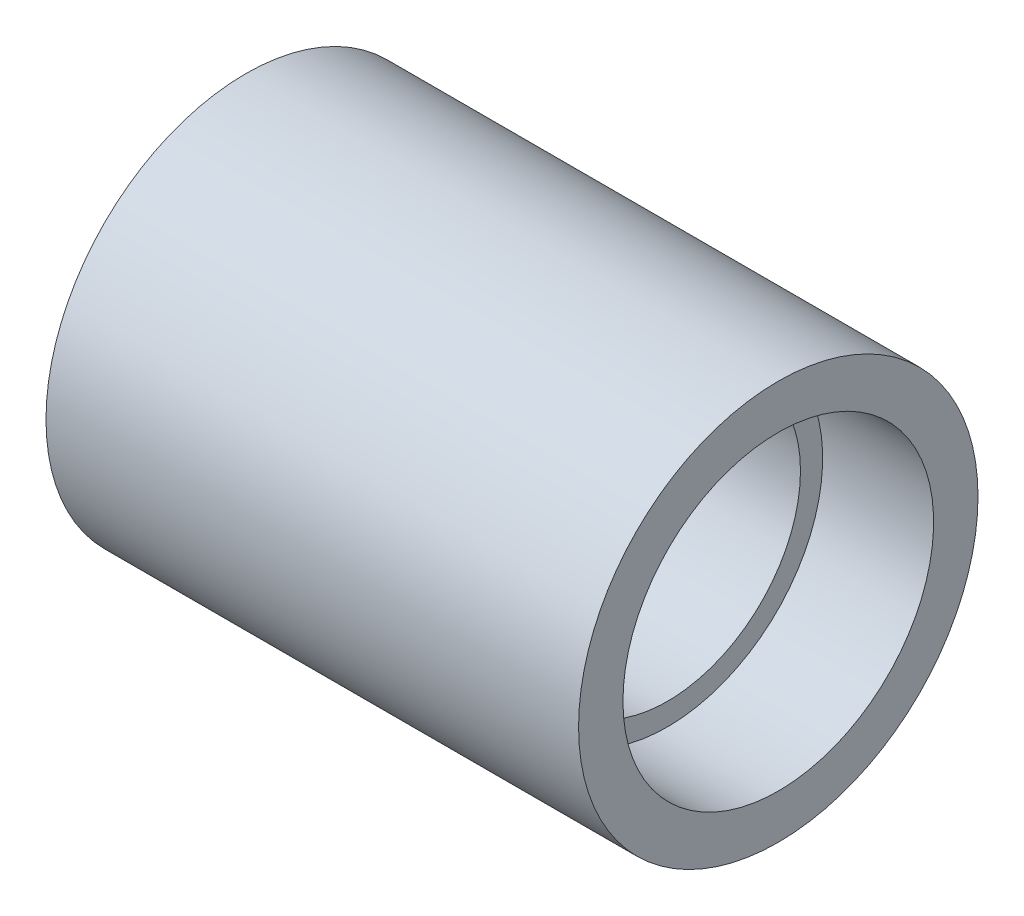
from build123d import *


with BuildPart() as part:
    # Skizze1 → Rotation1 (revolve)
    with BuildSketch(Plane.XY):
        Polygon((-6, 4.5), (-6, 3.5), (-3.5, 3.5), (-3.5, 3), (3.5, 3), (3.5, 3.5), (6, 3.5), (6, 4.5), align=None)
    revolve(axis=Axis((-8.508059036, 0, 0), (1, 0, 0)))


solid = part.part
